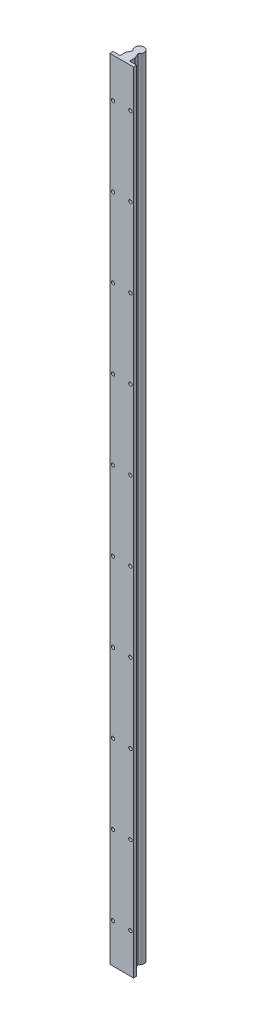
from build123d import *

# Parameters (mm, degrees)
BOSS_EXTRUDE1_DEPTH = 1000
SKETCH2_R           = 2.125
CUT_EXTRUDE1_DEPTH  = 5
LPATTERN1_COUNT     = 10
LPATTERN1_PITCH     = 100


with BuildPart() as part:
    # Sketch1 → Boss-Extrude1 (new body)
    with BuildSketch(Plane(origin=(0, 0, 0), x_dir=(1, 0, 0), z_dir=(0, 1, 0))):
        with BuildLine():
            Line((15, -22.5), (-15, -22.5))
            Line((-15, -22.5), (-15, -18.5))
            Line((-15, -18.5), (-6, -18.5))
            Line((-6, -18.5), (-6, -11.5))
            Line((-6, -11.5), (-3.25, -5.04356025))
            ThreePointArc((-3.25, -5.04356025), (0, 6), (3.25, -5.04356025))
            Line((3.25, -5.04356025), (6, -11.5))
            Line((6, -11.5), (6, -18.5))
            Line((6, -18.5), (15, -18.5))
            Line((15, -18.5), (15, -22.5))
        make_face()
    extrude(amount=BOSS_EXTRUDE1_DEPTH)

    # Sketch2 → Cut-Extrude1 (cut, through all)
    with BuildSketch(Plane(origin=(0, 0, 18.5), x_dir=(-1, 0, 0), z_dir=(0, 0, -1))):
        with Locations((-11, 950)):
            Circle(SKETCH2_R)
        with Locations((11, 950)):
            Circle(SKETCH2_R)
    cut_extrude1 = extrude(amount=-CUT_EXTRUDE1_DEPTH, mode=Mode.SUBTRACT)

    # LPattern1: Cut-Extrude1 ×10
    with Locations(*[(0, -i * LPATTERN1_PITCH, 0) for i in range(1, LPATTERN1_COUNT)]):
        add(cut_extrude1, mode=Mode.SUBTRACT)


solid = part.part
